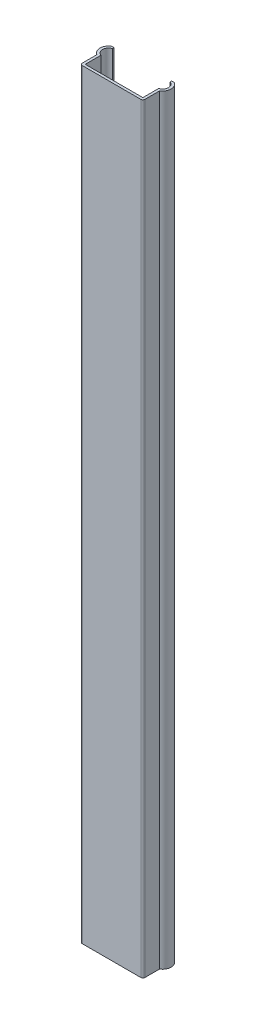
from build123d import *

# Parameters (mm, degrees)
EXTRUSION1_DEPTH = 182
CONG_1_R         = 0.5


with BuildPart() as part:
    # Esquisse1 → Extrusion1 (new body)
    with BuildSketch(Plane(origin=(0, 0, 0), x_dir=(1, 0, 0), z_dir=(0, 1, 0))):
        with BuildLine():
            Line((7.5, 0), (-7.5, 0))
            Line((-7.5, 0), (-7.5, 4))
            ThreePointArc((-7.5, 4), (-8.5, 5.75), (-7.5, 7.5))
            Line((-7.5, 7.5), (-6.9, 7.5))
            Line((-6.9, 7.5), (-6.9, 7.114734406))
            ThreePointArc((-6.9, 7.114734406), (-7.9, 5.75), (-6.9, 4.385265594))
            Line((-6.9, 4.385265594), (-6.9, 0.6))
            Line((-6.9, 0.6), (6.9, 0.6))
            Line((6.9, 0.6), (6.9, 4.385265594))
            ThreePointArc((6.9, 4.385265594), (7.9, 5.75), (6.9, 7.114734406))
            Line((6.9, 7.114734406), (6.9, 7.5))
            Line((6.9, 7.5), (7.5, 7.5))
            ThreePointArc((7.5, 7.5), (8.5, 5.75), (7.5, 4))
            Line((7.5, 4), (7.5, 0))
        make_face()
    extrude(amount=EXTRUSION1_DEPTH)

    # Congé1
    cong_1_edges = [part.edges().sort_by_distance(p)[0] for p in [
        (7.5, 91, 0),
        (-7.5, 91, 0),
    ]]
    fillet(cong_1_edges, radius=CONG_1_R)


solid = part.part
